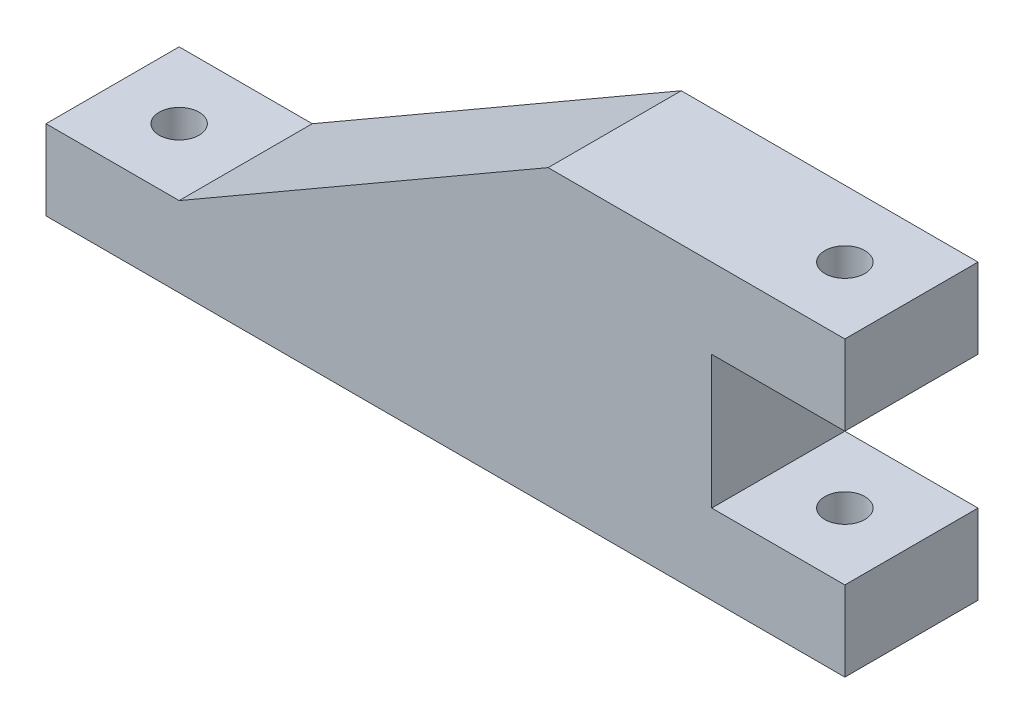
from build123d import *

# Parameters (mm, degrees)
BOSS_EXTRUDE1_DEPTH     = 50
SKETCH2_R               = 7.5
CUT_EXTRUDE1_DEPTH      = 81
CUT_EXTRUDE1_DEPTH_BACK = 31


with BuildPart() as part:
    # Sketch1 → Boss-Extrude1 (new body)
    with BuildSketch(Plane.XY):
        Polygon((-300, 0), (0, 0), (0, 30), (-50, 30), (-50, 80), (0, 80), (0, 110), (-111.435935394, 110), (-250, 30), (-300, 30), align=None)
    extrude(amount=BOSS_EXTRUDE1_DEPTH)

    # Sketch2 → Cut-Extrude1 (cut, two sides)
    with BuildSketch(Plane(origin=(0, 30, 0), x_dir=(1, 0, 0), z_dir=(0, 1, 0))) as cut_extrude1_sk:
        with Locations((-275, -25)):
            Circle(SKETCH2_R)
        with Locations((-25, -25)):
            Circle(SKETCH2_R)
    extrude(amount=CUT_EXTRUDE1_DEPTH, mode=Mode.SUBTRACT)
    extrude(cut_extrude1_sk.sketch, amount=-CUT_EXTRUDE1_DEPTH_BACK, mode=Mode.SUBTRACT)


solid = part.part
